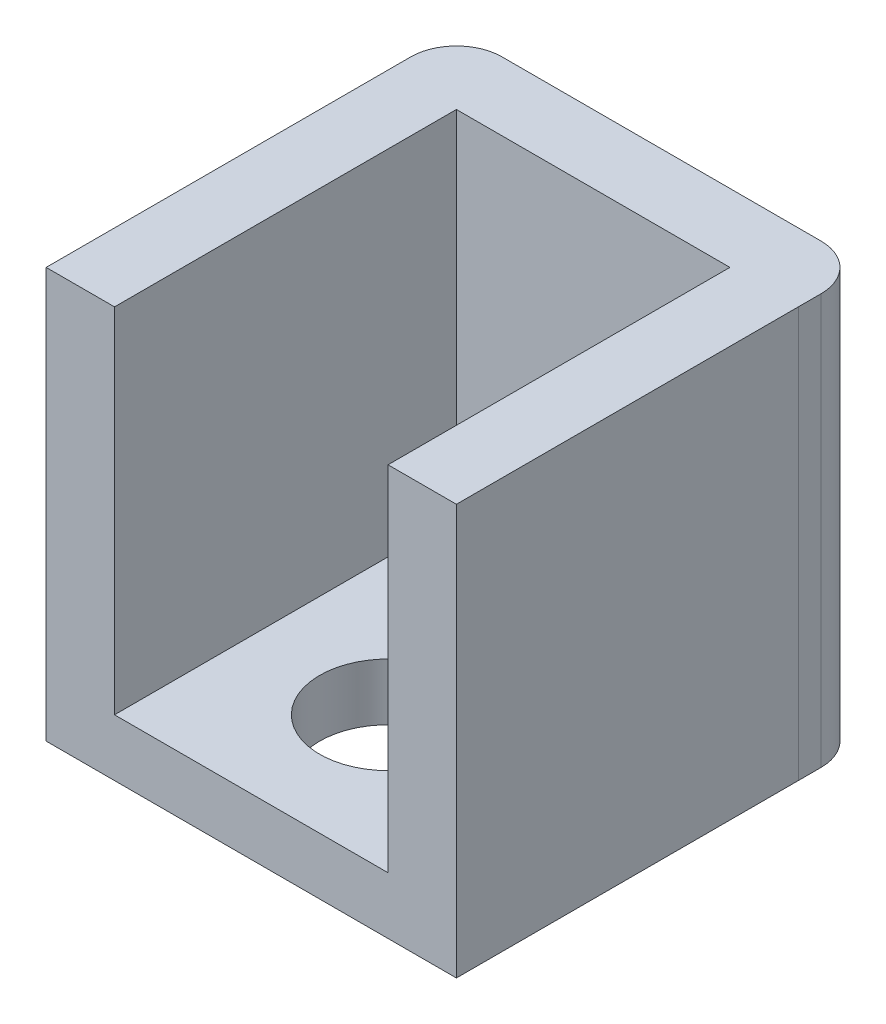
from build123d import *

# Parameters (mm, degrees)
SKETCH1_W           = 18
SKETCH1_H           = 18
BOSS_EXTRUDE2_DEPTH = 3
SKETCH2_W           = 3
SKETCH2_H           = 18
BOSS_EXTRUDE3_DEPTH = 15
SKETCH3_W           = 3
SKETCH3_H           = 18
BOSS_EXTRUDE4_DEPTH = 15
SKETCH5_W           = 11.999914095
SKETCH5_H           = 2.5
BOSS_EXTRUDE5_DEPTH = 15
FILLET1_R           = 2
FILLET2_R           = 2
SKETCH6_R           = 3
CUT_EXTRUDE1_DEPTH  = 19


with BuildPart() as part:
    # Sketch1 → Boss-Extrude2 (new body)
    with BuildSketch(Plane.XY):
        with Locations((9, 9)):
            Rectangle(SKETCH1_W, SKETCH1_H)
    extrude(amount=BOSS_EXTRUDE2_DEPTH)

    # Sketch2 → Boss-Extrude3 (add)
    with BuildSketch(Plane.XY.offset(3)):
        with Locations((16.499914095, 9)):
            Rectangle(SKETCH2_W, SKETCH2_H)
    extrude(amount=BOSS_EXTRUDE3_DEPTH)

    # Sketch3 → Boss-Extrude4 (add)
    with BuildSketch(Plane.XY.offset(3)):
        with Locations((1.5, 9)):
            Rectangle(SKETCH3_W, SKETCH3_H)
    extrude(amount=BOSS_EXTRUDE4_DEPTH)

    # Sketch5 → Boss-Extrude5 (add)
    with BuildSketch(Plane.XY.offset(3)):
        with Locations((8.999957048, 1.25)):
            Rectangle(SKETCH5_W, SKETCH5_H)
    extrude(amount=BOSS_EXTRUDE5_DEPTH)

    # Fillet1
    fillet1_edges = [part.edges().sort_by_distance(p)[0] for p in [
        (0, 9, 0),
    ]]
    fillet(fillet1_edges, radius=FILLET1_R)

    # Fillet2
    fillet2_edges = [part.edges().sort_by_distance(p)[0] for p in [
        (18, 9, 0),
    ]]
    fillet(fillet2_edges, radius=FILLET2_R)

    # Sketch6 → Cut-Extrude1 (cut, through all)
    with BuildSketch(Plane.XZ):
        with Locations((8.999957047, 12)):
            Circle(SKETCH6_R)
    extrude(amount=-CUT_EXTRUDE1_DEPTH, mode=Mode.SUBTRACT)


solid = part.part
